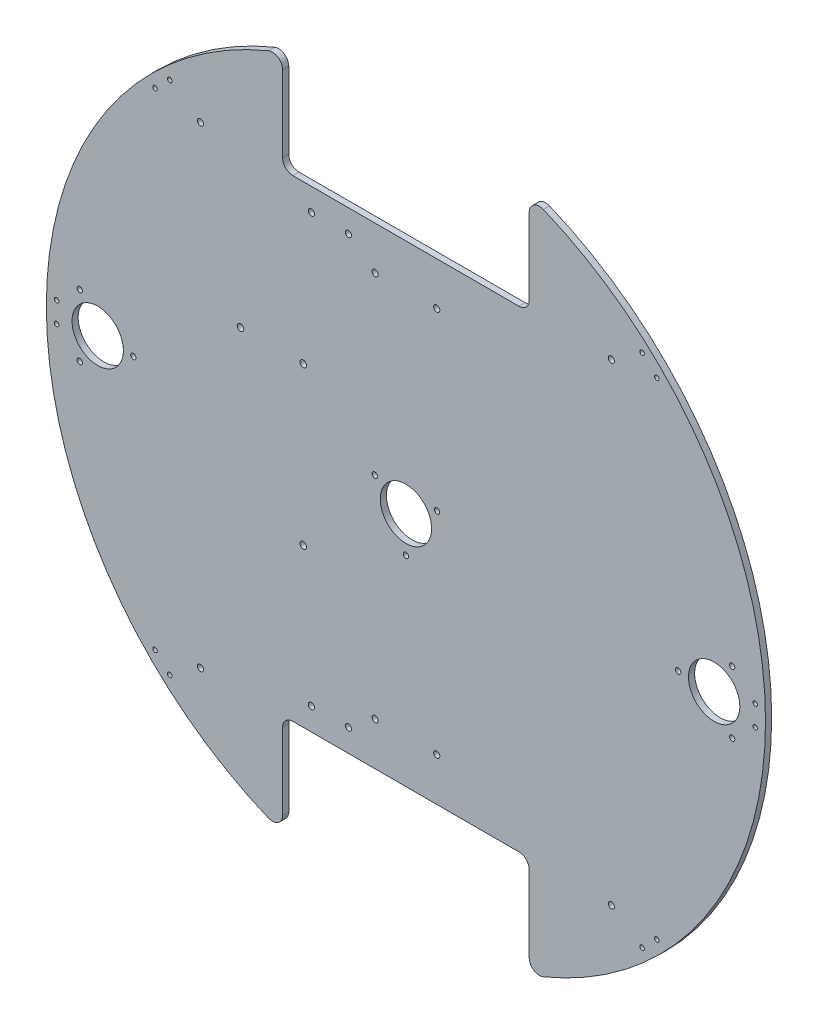
from build123d import *

# Parameters (mm, degrees)
SKETCH_1_R           = 175
EXTRUDE_1_DEPTH      = 3
CUT_EXTRUDE_1_DEPTH  = 3
FILLET_1_R           = 5
FILLET_2_R           = 5
FILLET_3_R           = 5
SKETCH_5_R           = 1.5
CUT_EXTRUDE_4_DEPTH  = 3
SKETCH_10_R          = 12.5
SKETCH_10_R_2        = 1.3
CUT_EXTRUDE_13_DEPTH = 10
SKETCH_14_R          = 1.1
CUT_EXTRUDE_14_DEPTH = 10
SKETCH_12_R          = 1.5
CUT_EXTRUDE_17_DEPTH = 10
SKETCH_13_R          = 1.5
CUT_EXTRUDE_18_DEPTH = 5
SKETCH_17_R          = 1.1
CUT_EXTRUDE_19_DEPTH = 10
SKETCH_18_R          = 1.6
CUT_EXTRUDE_20_DEPTH = 10


with BuildPart() as part:
    # ｽｹｯﾁ1 → ﾎﾞｽ - 押し出し1 (new body)
    with BuildSketch(Plane.XY):
        Circle(SKETCH_1_R)
    extrude(amount=EXTRUDE_1_DEPTH)

    # ｽｹｯﾁ2 → ｶｯﾄ - 押し出し1 (cut)
    with BuildSketch(Plane.XY.offset(3)):
        with BuildLine():
            Line((-60, 115), (0, 115))
            Line((0, 115), (0, 175))
            ThreePointArc((0, 175), (-30.465194158, 172.327803749), (-60, 164.392822228))
            Line((-60, 164.392822228), (-60, 115))
        make_face()
        with BuildLine():
            Line((0, 175), (0, 115))
            Line((0, 115), (60, 115))
            Line((60, 115), (60, 164.392822228))
            ThreePointArc((60, 164.392822228), (30.465194158, 172.327803749), (0, 175))
        make_face()
        with BuildLine():
            Line((0, -175), (0, -115))
            Line((0, -115), (-60, -115))
            Line((-60, -115), (-60, -164.392822228))
            ThreePointArc((-60, -164.392822228), (-30.465194158, -172.327803749), (0, -175))
        make_face()
        with BuildLine():
            Line((60, -115), (0, -115))
            Line((0, -115), (0, -175))
            ThreePointArc((0, -175), (30.465194158, -172.327803749), (60, -164.392822228))
            Line((60, -164.392822228), (60, -115))
        make_face()
    extrude(amount=-CUT_EXTRUDE_1_DEPTH, mode=Mode.SUBTRACT)

    # ﾌｨﾚｯﾄ1
    fillet_1_edges = [part.edges().sort_by_distance(p)[0] for p in [
        (-60, 164.392822228, 1.5),
    ]]
    fillet(fillet_1_edges, radius=FILLET_1_R)

    # ﾌｨﾚｯﾄ2
    fillet_2_edges = [part.edges().sort_by_distance(p)[0] for p in [
        (-60, 115, 1.5),
        (60, 164.392822228, 1.5),
        (60, 115, 1.5),
    ]]
    fillet(fillet_2_edges, radius=FILLET_2_R)

    # ﾌｨﾚｯﾄ3
    fillet_3_edges = [part.edges().sort_by_distance(p)[0] for p in [
        (-60, -115, 1.5),
        (60, -115, 1.5),
        (60, -164.392822228, 1.5),
        (-60, -164.392822228, 1.5),
    ]]
    fillet(fillet_3_edges, radius=FILLET_3_R)

    # ｽｹｯﾁ5 → ｶｯﾄ - 押し出し4 (cut)
    with BuildSketch(Plane.XY.offset(3)):
        with Locations((-100, -115)):
            Circle(SKETCH_5_R)
        with Locations((100, -115)):
            Circle(SKETCH_5_R)
        with Locations((100, 115)):
            Circle(SKETCH_5_R)
        with Locations((-100, 115)):
            Circle(SKETCH_5_R)
    extrude(amount=-CUT_EXTRUDE_4_DEPTH, mode=Mode.SUBTRACT)

    # ｽｹｯﾁ10 → ｶｯﾄ - 押し出し13 (cut)
    with BuildSketch(Plane.XY.offset(3)):
        with Locations((-150, 0)):
            Circle(SKETCH_10_R)
        with Locations((150, 0)):
            Circle(SKETCH_10_R)
        Circle(SKETCH_10_R)
        with Locations((132.5, 0)):
            Circle(SKETCH_10_R_2)
        with Locations((158.75, 15.155444566)):
            Circle(SKETCH_10_R_2)
        with Locations((158.75, -15.155444566)):
            Circle(SKETCH_10_R_2)
        with Locations((-15.155444566, 8.75)):
            Circle(SKETCH_10_R_2)
        with Locations((15.155444566, 8.75)):
            Circle(SKETCH_10_R_2)
        with Locations((0, -17.5)):
            Circle(SKETCH_10_R_2)
        with Locations((-158.75, 15.155444566)):
            Circle(SKETCH_10_R_2)
        with Locations((-158.75, -15.155444566)):
            Circle(SKETCH_10_R_2)
        with Locations((-132.632898389, 0)):
            Circle(SKETCH_10_R_2)
    extrude(amount=-CUT_EXTRUDE_13_DEPTH, mode=Mode.SUBTRACT)

    # ｽｹｯﾁ14 → ｶｯﾄ - 押し出し14 (cut)
    with BuildSketch(Plane.XY.offset(3)):
        with Locations((-170, 5)):
            Circle(SKETCH_14_R)
        with Locations((-170, -5)):
            Circle(SKETCH_14_R)
        with Locations((-114.933514447, 125.360628815)):
            Circle(SKETCH_14_R)
        with Locations((-122.102620524, 118.388977786)):
            Circle(SKETCH_14_R)
        with Locations((-122.102620524, -118.388977786)):
            Circle(SKETCH_14_R)
        with Locations((-114.933514447, -125.360628815)):
            Circle(SKETCH_14_R)
    extrude(amount=-CUT_EXTRUDE_14_DEPTH, mode=Mode.SUBTRACT)

    # ｽｹｯﾁ12 → ｶｯﾄ - 押し出し17 (cut)
    with BuildSketch(Plane.XY.offset(3)):
        with Locations((-15, 94)):
            Circle(SKETCH_12_R)
        with Locations((15, 94)):
            Circle(SKETCH_12_R)
        with Locations((-15, -94)):
            Circle(SKETCH_12_R)
        with Locations((15, -94)):
            Circle(SKETCH_12_R)
    extrude(amount=-CUT_EXTRUDE_17_DEPTH, mode=Mode.SUBTRACT)

    # ｽｹｯﾁ13 → ｶｯﾄ - 押し出し18 (cut)
    with BuildSketch(Plane.XY.offset(3)):
        with Locations((-28, -104)):
            Circle(SKETCH_13_R)
        with Locations((-46, -104)):
            Circle(SKETCH_13_R)
        with Locations((-46, 104)):
            Circle(SKETCH_13_R)
        with Locations((-28, 104)):
            Circle(SKETCH_13_R)
    extrude(amount=-CUT_EXTRUDE_18_DEPTH, mode=Mode.SUBTRACT)

    # ｽｹｯﾁ17 → ｶｯﾄ - 押し出し19 (cut)
    with BuildSketch(Plane.XY.offset(3)):
        with Locations((170, 5)):
            Circle(SKETCH_17_R)
        with Locations((170, -5)):
            Circle(SKETCH_17_R)
        with Locations((114.933514447, 125.360628815)):
            Circle(SKETCH_17_R)
        with Locations((122.102620524, 118.388977786)):
            Circle(SKETCH_17_R)
        with Locations((122.102620524, -118.388977786)):
            Circle(SKETCH_17_R)
        with Locations((114.933514447, -125.360628815)):
            Circle(SKETCH_17_R)
    extrude(amount=-CUT_EXTRUDE_19_DEPTH, mode=Mode.SUBTRACT)

    # ｽｹｯﾁ18 → ｶｯﾄ - 押し出し20 (cut)
    with BuildSketch(Plane.XY.offset(3)):
        with Locations((-50, 38.25)):
            Circle(SKETCH_18_R)
        with Locations((-80.5, 38.25)):
            Circle(SKETCH_18_R)
        with Locations((-50, -38.25)):
            Circle(SKETCH_18_R)
    extrude(amount=-CUT_EXTRUDE_20_DEPTH, mode=Mode.SUBTRACT)


solid = part.part
